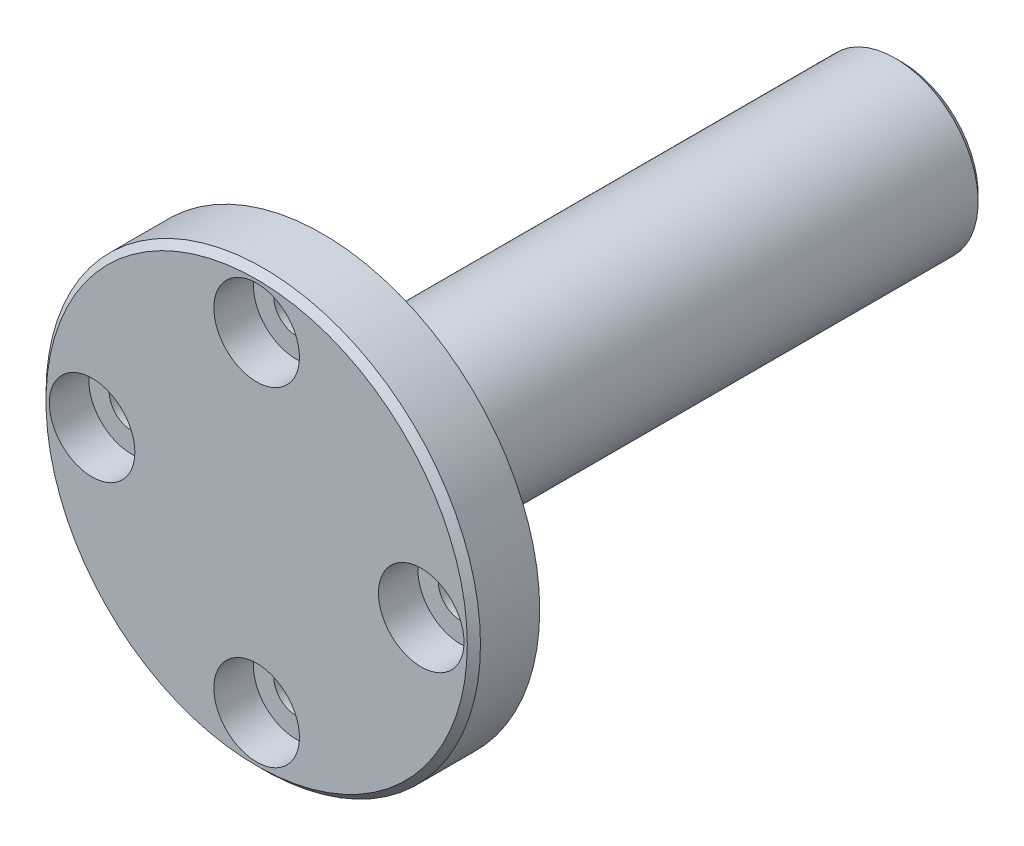
from build123d import *

# Parameters (mm, degrees)
HOLE_WIZARD_M31_D           = 3.4
HOLE_WIZARD_M31_CBORE_D     = 6.5
HOLE_WIZARD_M31_CBORE_DEPTH = 3
M3X0_51_D                   = 2.5
M3X0_51_DEPTH               = 15
M3X0_51_TIP                 = 0.751075774
CHAMFER_1_SIZE              = 0.5


with BuildPart() as part:
    # Эскиз2 → Повернуть1 (revolve)
    with BuildSketch(Plane(origin=(0, 0, 0), x_dir=(0, 0, -1), z_dir=(1, 0, 0))):
        Polygon((0, 0), (0, 16.5), (5, 16.5), (5, 6.3), (49, 6.3), (49, 0), align=None)
    revolve(axis=Axis((0, 0, -49), (0, 0, 1)))

    # Цековка для винта с внутренним шестигранником M31 (through all)
    with Locations(Plane.XY):
        with Locations((-12.5, 0), (0, 12.5), (12.5, 0), (0, -12.5)):
            CounterBoreHole(HOLE_WIZARD_M31_D / 2, HOLE_WIZARD_M31_CBORE_D / 2, HOLE_WIZARD_M31_CBORE_DEPTH)

    # Отверстие обработанное метчиком M3x0.51
    with Locations(Plane(origin=(2.706733298, -7.232806727, -49), x_dir=(-0.635524995, -0.772080294, 0), z_dir=(0, 0, -1))):
        with Locations((-3.864110878, 6.686444901)):
            Hole(M3X0_51_D / 2, depth=M3X0_51_DEPTH)
            with Locations((0, 0, -(M3X0_51_DEPTH + M3X0_51_TIP / 2))):  # 118° drill point
                Cone(0, M3X0_51_D / 2, M3X0_51_TIP, mode=Mode.SUBTRACT)

    # Фаска1
    chamfer_1_edges = [part.edges().sort_by_distance(p)[0] for p in [
        (0, -6.3, -49),
        (0, -16.5, 0),
    ]]
    chamfer(chamfer_1_edges, length=CHAMFER_1_SIZE)


solid = part.part
